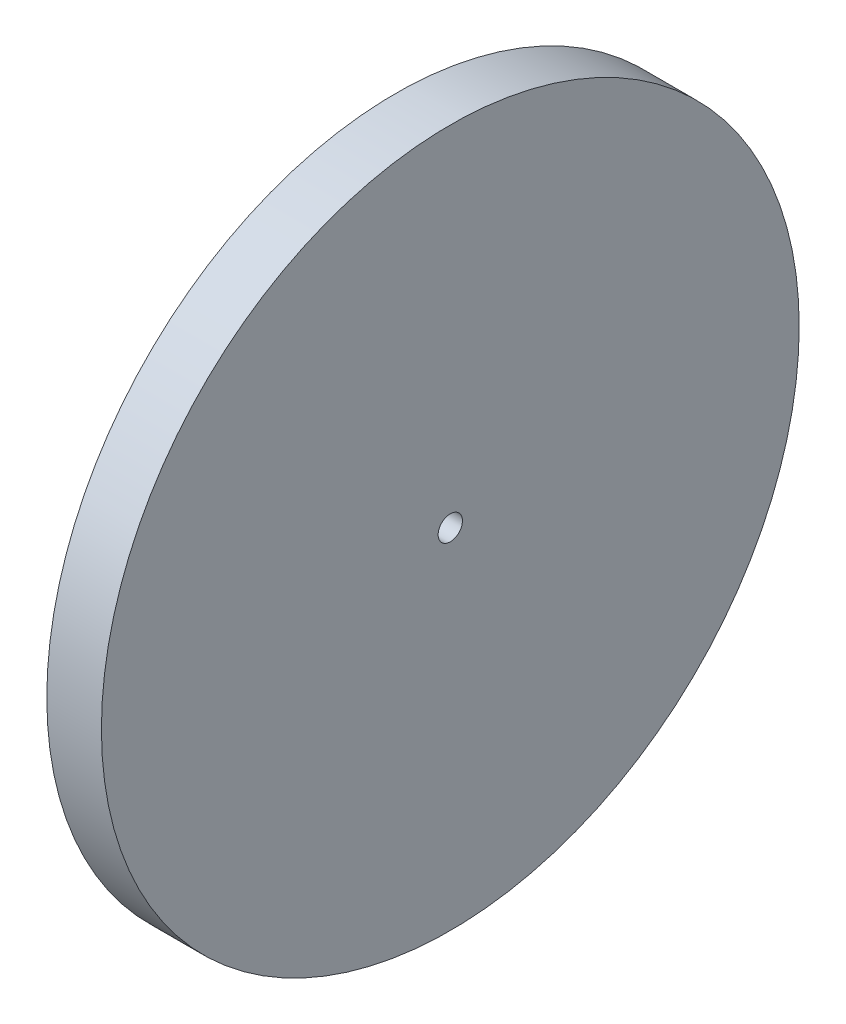
from build123d import *

# Parameters (mm, degrees)
BASPROSKE_W                         = 6
BASPROSKE_H                         = 9.5
TOOTHCUT_DEPTH                      = 82.538334543
TEETHCUTS_COUNT                     = 50
ESQUISSE1_R                         = 57.5
ESQUISSE1_R_2                       = 2
BOSS_EXTRU_1_DEPTH                  = 3
ESQUISSE2_R                         = 10
ESQUISSE2_R_2                       = 2
BOSS_EXTRU_2_DEPTH                  = 10
ESQUISSE3_W                         = 5.5
ESQUISSE3_H                         = 2
ENL_V_MAT_EXTRU_1_DEPTH             = 7
ENL_V_MAT_EXTRU_2_REACH             = 86.673
ESQUISSE4_R                         = 1.5
ENL_V_MAT_EXTRU_2_DIRECTION_2_REACH = 86.673


with BuildPart() as part:
    # BasProSke → Base-Revolve (revolve)
    with BuildSketch(Plane(origin=(0, 0, 0), x_dir=(1, 0, 0), z_dir=(0, 1, 0)), mode=Mode.PRIVATE) as base_revolve_sk:
        with Locations((3, 52.75)):
            Rectangle(BASPROSKE_W, BASPROSKE_H)
    revolve(base_revolve_sk.sketch.rotate(Axis((-10, 0, 0), (1, 0, 0)), 180), axis=Axis((-10, 0, 0), (1, 0, 0)))

    # TooCutSke → ToothCut (cut, through all)
    with BuildSketch(Plane(origin=(0, 0, 0), x_dir=(0, 0, -1), z_dir=(1, 0, 0))):
        with BuildLine():
            ThreePointArc((2.426707814, 47.913185391), (1.628356337, 50.250450788), (0.603274723, 52.497533853))
            ThreePointArc((0.603274723, 52.497533853), (0, 52.501), (-0.603274723, 52.497533853))
            ThreePointArc((-0.603274723, 52.497533853), (-1.628356337, 50.250450788), (-2.426707814, 47.913185391))
            ThreePointArc((-2.426707814, 47.913185391), (0, 47.9746), (2.426707814, 47.913185391))
        make_face()
    toothcut = extrude(amount=TOOTHCUT_DEPTH, mode=Mode.SUBTRACT)

    # TeethCuts: ToothCut ×50 about axis
    teethcuts_axis = Axis((0, 0, 0), (1, 0, 0))
    for i in range(1, TEETHCUTS_COUNT):
        add(toothcut.rotate(teethcuts_axis, i * 360 / TEETHCUTS_COUNT), mode=Mode.SUBTRACT)

    # Esquisse1 → Boss.-Extru.1 (add)
    with BuildSketch(Plane(origin=(6, 0, 0), x_dir=(0, 0, -1), z_dir=(1, 0, 0))):
        with Locations(Location((0, 0, 0), (0, 0, 180))):
            Circle(ESQUISSE1_R)
        Circle(ESQUISSE1_R_2, mode=Mode.SUBTRACT)
    extrude(amount=BOSS_EXTRU_1_DEPTH)

    # Esquisse2 → Boss.-Extru.2 (add)
    with BuildSketch(Plane.ZY.offset(-6)):
        with Locations(Location((0, 0, 0), (0, 0, 180))):
            Circle(ESQUISSE2_R)
        Circle(ESQUISSE2_R_2, mode=Mode.SUBTRACT)
    extrude(amount=BOSS_EXTRU_2_DEPTH)

    # Esquisse3 → Enlèv. mat.-Extru.1 (cut)
    with BuildSketch(Plane.ZY.offset(4)):
        with Locations((0, 5)):
            Rectangle(ESQUISSE3_W, ESQUISSE3_H)
    extrude(amount=-ENL_V_MAT_EXTRU_1_DEPTH, mode=Mode.SUBTRACT)

    # Esquisse4 → Enlèv. mat.-Extru.2 (cut, up to next)
    with BuildSketch(Plane(origin=(0, 4, 0), x_dir=(1, 0, 0), z_dir=(0, 1, 0)), mode=Mode.PRIVATE) as enl_v_mat_extru_2_sk1:
        with Locations(Location((0, 0, 0), (0, 0, 90))):
            Circle(ESQUISSE4_R)
    enl_v_mat_extru_2_tool1 = extrude(enl_v_mat_extru_2_sk1.sketch, amount=-ENL_V_MAT_EXTRU_2_REACH, mode=Mode.PRIVATE) & part.part
    add(enl_v_mat_extru_2_tool1.solids().sort_by_distance((0, 4, 0))[0], mode=Mode.SUBTRACT)

    # Esquisse4 → Enlèv. mat.-Extru.2 direction 2 (cut, up to next)
    with BuildSketch(Plane(origin=(0, 4, 0), x_dir=(1, 0, 0), z_dir=(0, 1, 0)), mode=Mode.PRIVATE) as enl_v_mat_extru_2_direction_2_sk1:
        with Locations(Location((0, 0, 0), (0, 0, 90))):
            Circle(ESQUISSE4_R)
    enl_v_mat_extru_2_direction_2_tool1 = extrude(enl_v_mat_extru_2_direction_2_sk1.sketch, amount=ENL_V_MAT_EXTRU_2_DIRECTION_2_REACH, mode=Mode.PRIVATE) & part.part
    add(enl_v_mat_extru_2_direction_2_tool1.solids().sort_by_distance((0, 4, 0))[0], mode=Mode.SUBTRACT)


solid = part.part
